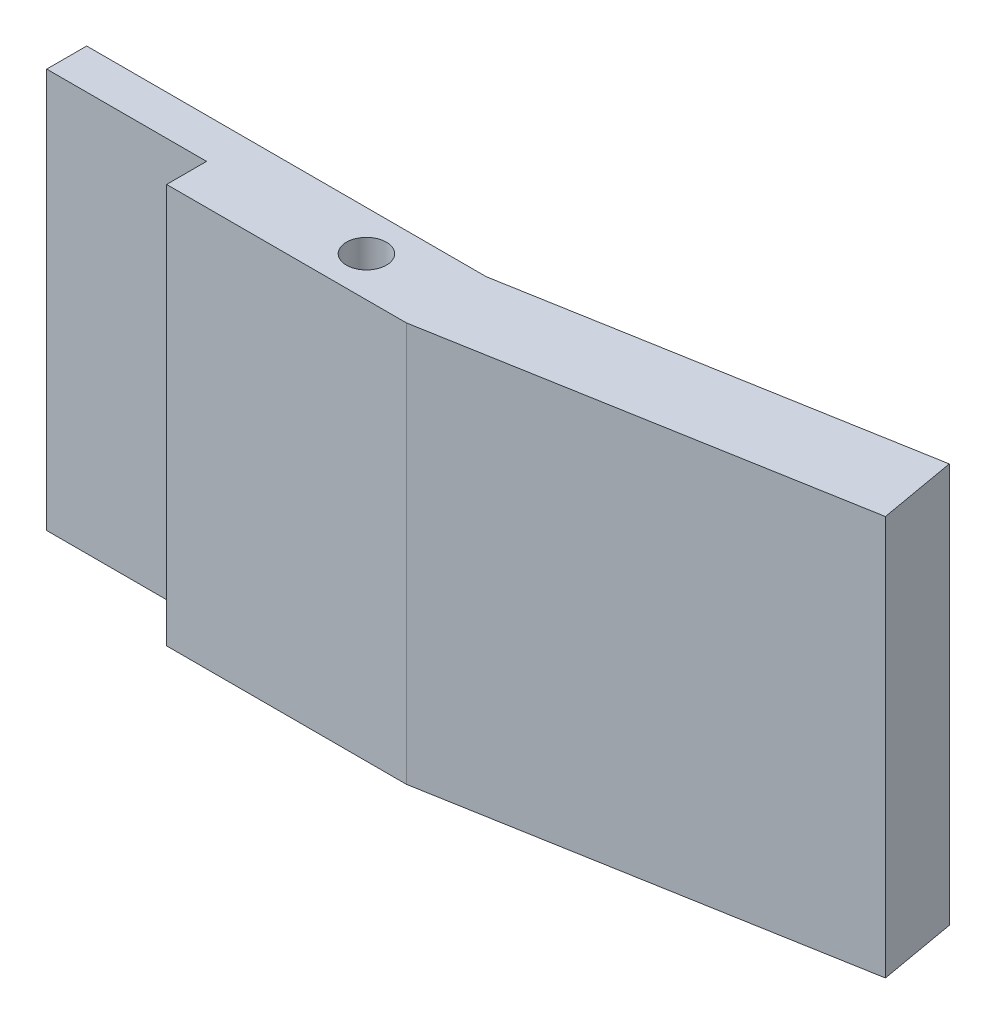
from build123d import *

# Parameters (mm, degrees)
SKETCH1_R           = 1.5875
BOSS_EXTRUDE1_DEPTH = 31.75


with BuildPart() as part:
    # Sketch1 → Boss-Extrude1 (new body)
    with BuildSketch(Plane(origin=(0, 0, 0), x_dir=(1, 0, 0), z_dir=(0, 1, 0))):
        Polygon((12.7, -6.35), (31.75, -6.35), (64.103560113, -0.64519443), (63.017646158, 5.513329641), (31.75, 0), (0, 0), (0, -3.175), (12.7, -3.175), align=None)
        with Locations((25.4, -3.175)):
            Circle(SKETCH1_R, mode=Mode.SUBTRACT)
    extrude(amount=BOSS_EXTRUDE1_DEPTH)


solid = part.part
